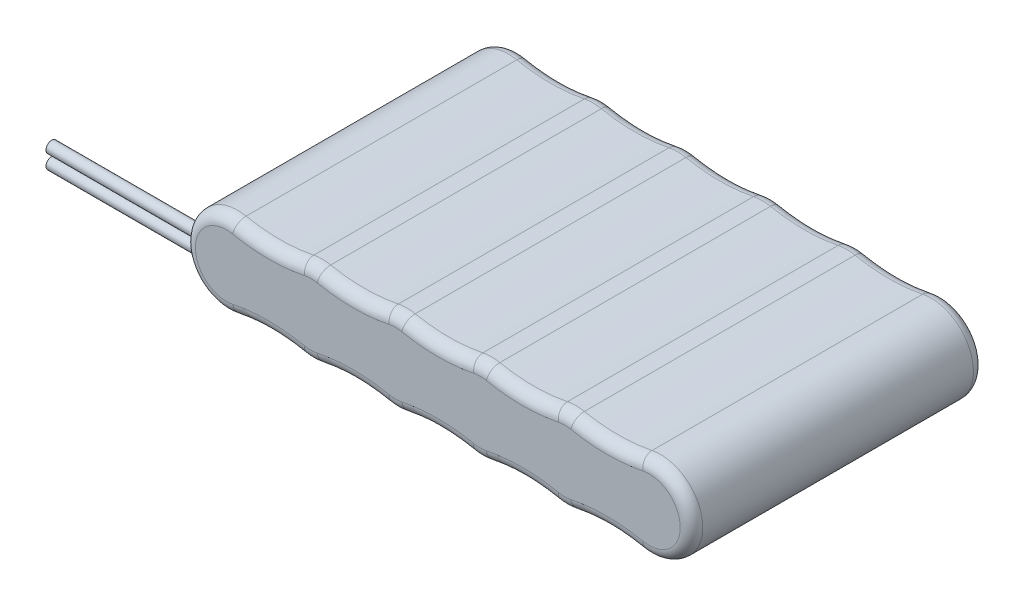
from build123d import *

# Parameters (mm, degrees)
BOSS_EXTRU_1_DEPTH = 52
CONG_1_R           = 2
ESQUISSE3_R        = 1
BOSS_EXTRU_2_DEPTH = 40


with BuildPart() as part:
    # Esquisse2 → Boss.-Extru.1 (new body)
    with BuildSketch(Plane.XY):
        with BuildLine():
            ThreePointArc((6, 7.348469228), (0, 6.742346142), (-6, 7.348469228))
            ThreePointArc((-6, 7.348469228), (-15, 0), (-6, -7.348469228))
            ThreePointArc((-6, -7.348469228), (0, -6.742346142), (6, -7.348469228))
            ThreePointArc((6, -7.348469228), (0, 0), (6, 7.348469228))
        make_face()
        with BuildLine():
            ThreePointArc((9, 7.348469228), (7.5, 7.5), (6, 7.348469228))
            ThreePointArc((6, 7.348469228), (0, 0), (6, -7.348469228))
            ThreePointArc((6, -7.348469228), (7.5, -7.5), (9, -7.348469228))
            ThreePointArc((9, -7.348469228), (13.309475024, -4.743416484), (15, 1.6e-08))
            ThreePointArc((15, 1.6e-08), (13.309475014, 4.743416497), (9, 7.348469228))
        make_face()
        with BuildLine():
            ThreePointArc((21, 7.348469228), (15, 6.742346142), (9, 7.348469228))
            ThreePointArc((9, 7.348469228), (13.309475014, 4.743416497), (15, 1.6e-08))
            ThreePointArc((15, 1.6e-08), (16.690524986, 4.743416497), (21, 7.348469228))
        make_face()
        with BuildLine():
            ThreePointArc((15, 1.6e-08), (13.309475024, -4.743416484), (9, -7.348469228))
            ThreePointArc((9, -7.348469228), (15, -6.742346142), (21, -7.348469228))
            ThreePointArc((21, -7.348469228), (16.690524976, -4.743416484), (15, 1.6e-08))
        make_face()
        with BuildLine():
            ThreePointArc((21, 7.348469228), (16.690524986, 4.743416497), (15, 1.6e-08))
            ThreePointArc((15, 1.6e-08), (16.690524976, -4.743416484), (21, -7.348469228))
            ThreePointArc((21, -7.348469228), (22.5, -7.5), (24, -7.348469228))
            ThreePointArc((24, -7.348469228), (28.309475025, -4.743416484), (30, 1.7e-08))
            ThreePointArc((30, 1.7e-08), (28.309475014, 4.743416497), (24, 7.348469228))
            ThreePointArc((24, 7.348469228), (22.5, 7.5), (21, 7.348469228))
        make_face()
        with BuildLine():
            ThreePointArc((36, 7.348469228), (30, 6.742346142), (24, 7.348469228))
            ThreePointArc((24, 7.348469228), (28.309475014, 4.743416497), (30, 1.7e-08))
            ThreePointArc((30, 1.7e-08), (31.690524986, 4.743416497), (36, 7.348469228))
        make_face()
        with BuildLine():
            ThreePointArc((30, 1.7e-08), (28.309475025, -4.743416484), (24, -7.348469228))
            ThreePointArc((24, -7.348469228), (30, -6.742346142), (36, -7.348469228))
            ThreePointArc((36, -7.348469228), (31.690524975, -4.743416484), (30, 1.7e-08))
        make_face()
        with BuildLine():
            ThreePointArc((36, 7.348469228), (31.690524986, 4.743416497), (30, 1.7e-08))
            ThreePointArc((30, 1.7e-08), (31.690524975, -4.743416484), (36, -7.348469228))
            ThreePointArc((36, -7.348469228), (37.5, -7.5), (39, -7.348469228))
            ThreePointArc((39, -7.348469228), (43.309475006, -4.743416507), (45, -4.3e-08))
            ThreePointArc((45, -4.3e-08), (43.309475033, 4.743416474), (39, 7.348469228))
            ThreePointArc((39, 7.348469228), (37.5, 7.5), (36, 7.348469228))
        make_face()
        with BuildLine():
            ThreePointArc((51, 7.348469228), (45, 6.742346142), (39, 7.348469228))
            ThreePointArc((39, 7.348469228), (43.309475033, 4.743416474), (45, -4.3e-08))
            ThreePointArc((45, -4.3e-08), (46.690524967, 4.743416474), (51, 7.348469228))
        make_face()
        with BuildLine():
            ThreePointArc((45, -4.3e-08), (43.309475006, -4.743416507), (39, -7.348469228))
            ThreePointArc((39, -7.348469228), (45, -6.742346142), (51, -7.348469228))
            ThreePointArc((51, -7.348469228), (46.690524994, -4.743416507), (45, -4.3e-08))
        make_face()
        with BuildLine():
            ThreePointArc((51, 7.348469228), (46.690524967, 4.743416474), (45, -4.3e-08))
            ThreePointArc((45, -4.3e-08), (46.690524994, -4.743416507), (51, -7.348469228))
            ThreePointArc((51, -7.348469228), (52.5, -7.5), (54, -7.348469228))
            ThreePointArc((54, -7.348469228), (60, 0), (54, 7.348469228))
            ThreePointArc((54, 7.348469228), (52.5, 7.5), (51, 7.348469228))
        make_face()
        with BuildLine():
            ThreePointArc((66, 7.348469228), (60, 6.742346142), (54, 7.348469228))
            ThreePointArc((54, 7.348469228), (60, 0), (54, -7.348469228))
            ThreePointArc((54, -7.348469228), (60, -6.742346142), (66, -7.348469228))
            ThreePointArc((66, -7.348469228), (75, 0), (66, 7.348469228))
        make_face()
    extrude(amount=BOSS_EXTRU_1_DEPTH)

    # Congé1
    cong_1_edges = [part.edges().sort_by_distance(p)[0] for p in [
        (7.5, -7.5, 52),
        (-15, 0, 52),
        (15, -6.742346142, 52),
        (22.5, -7.5, 52),
        (-15, 0, 0),
        (0, 6.742346142, 0),
        (7.5, 7.5, 0),
        (15, 6.742346142, 0),
        (22.5, 7.5, 0),
        (30, 6.742346142, 0),
        (37.5, 7.5, 0),
        (45, 6.742346142, 0),
        (52.5, 7.5, 0),
        (60, 6.742346142, 0),
        (30, -6.742346142, 52),
        (75, 0, 0),
        (60, -6.742346142, 0),
        (52.5, -7.5, 0),
        (45, -6.742346142, 0),
        (37.5, -7.5, 0),
        (30, -6.742346142, 0),
        (22.5, -7.5, 0),
        (15, -6.742346142, 0),
        (7.5, -7.5, 0),
        (0, -6.742346142, 0),
        (37.5, -7.5, 52),
        (45, -6.742346142, 52),
        (52.5, -7.5, 52),
        (60, -6.742346142, 52),
        (0, -6.742346142, 52),
        (75, 0, 52),
        (60, 6.742346142, 52),
        (52.5, 7.5, 52),
        (45, 6.742346142, 52),
        (37.5, 7.5, 52),
        (30, 6.742346142, 52),
        (22.5, 7.5, 52),
        (15, 6.742346142, 52),
        (7.5, 7.5, 52),
        (0, 6.742346142, 52),
    ]]
    fillet(cong_1_edges, radius=CONG_1_R)

    # Esquisse3 → Boss.-Extru.2 (add)
    with BuildSketch(Plane(origin=(0, 0, 0), x_dir=(0, 0, -1), z_dir=(1, 0, 0))):
        with Locations((-50.5, 1.25)):
            Circle(ESQUISSE3_R)
        with Locations((-50.5, -1.25)):
            Circle(ESQUISSE3_R)
    extrude(amount=-BOSS_EXTRU_2_DEPTH)


solid = part.part
